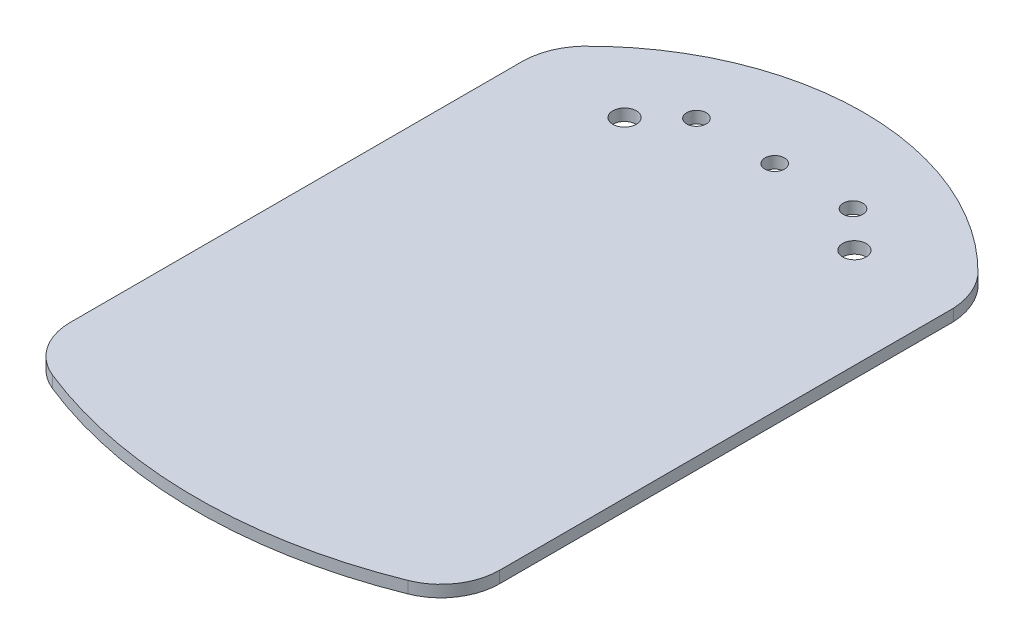
from build123d import *

# Parameters (mm, degrees)
SKETCH2_R           = 3
SKETCH2_R_2         = 2.5
BOSS_EXTRUDE1_DEPTH = 3


with BuildPart() as part:
    # Sketch2 → Boss-Extrude1 (new body)
    with BuildSketch(Plane(origin=(0, 0, 0), x_dir=(1, 0, 0), z_dir=(0, 1, 0))):
        with BuildLine():
            Line((-54.843939578, -82.950592443), (-54.843939578, 33.080710792))
            ThreePointArc((-54.843939578, 33.080710792), (-53.629479142, 38.690320935), (-50.582114931, 43.554086088))
            ThreePointArc((-50.582114931, 43.554086088), (0, 64.876726435), (50.582114931, 43.554086088))
            ThreePointArc((50.582114931, 43.554086088), (53.581553542, 38.670819055), (54.843939578, 33.080710792))
            Line((54.843939578, 33.080710792), (54.843939578, -82.950592443))
            ThreePointArc((54.843939578, -82.950592443), (52.270146994, -91.352340431), (45.432023677, -96.870840864))
            ThreePointArc((45.432023677, -96.870840864), (0, -105.649395093), (-45.432023677, -96.870840864))
            ThreePointArc((-45.432023677, -96.870840864), (-52.270146994, -91.352340431), (-54.843939578, -82.950592443))
        make_face()
        with Locations((29.359626422, 33.197024949)):
            Circle(SKETCH2_R, mode=Mode.SUBTRACT)
        with Locations((-29.359626422, 33.197024949)):
            Circle(SKETCH2_R, mode=Mode.SUBTRACT)
        with Locations((0, 42.202367755)):
            Circle(SKETCH2_R_2, mode=Mode.SUBTRACT)
        with Locations((20, 42.202367755)):
            Circle(SKETCH2_R_2, mode=Mode.SUBTRACT)
        with Locations((-20, 42.202367755)):
            Circle(SKETCH2_R_2, mode=Mode.SUBTRACT)
    extrude(amount=BOSS_EXTRUDE1_DEPTH)


solid = part.part
